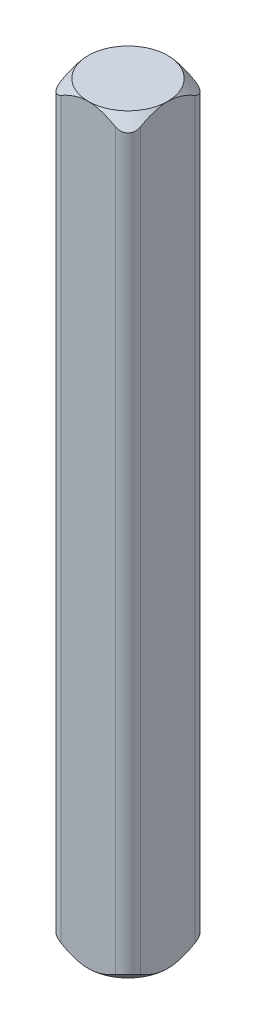
from build123d import *

# Parameters (mm, degrees)
SKETCH1_W           = 3.175
SKETCH1_H           = 3.175
BOSS_EXTRUDE1_DEPTH = 15
FILLET1_R           = 0.508


with BuildPart() as part:
    # Sketch1 → Boss-Extrude1 (new, symmetric)
    with BuildSketch(Plane(origin=(0, 0, 0), x_dir=(1, 0, 0), z_dir=(0, 1, 0))):
        Rectangle(SKETCH1_W, SKETCH1_H)
    extrude(amount=BOSS_EXTRUDE1_DEPTH, both=True)

    # Fillet1
    fillet1_edges = [part.edges().sort_by_distance(p)[0] for p in [
        (-1.5875, 0, -1.5875),
        (-1.5875, 0, 1.5875),
        (1.5875, 0, -1.5875),
        (1.5875, 0, 1.5875),
    ]]
    fillet(fillet1_edges, radius=FILLET1_R)

    # Sketch3 → Cut-Revolve3 (revolve, cut)
    with BuildSketch(Plane.XY):
        Polygon((1.5875, -15), (2.294606781, -14.292893219), (2.294606781, -16), (1.5875, -16), align=None)
    cut_revolve3 = revolve(axis=Axis((0, 0, 0), (0, -1, 0)), mode=Mode.SUBTRACT)

    # Mirror1: Cut-Revolve3 across plane
    add(cut_revolve3.mirror(Plane.ZX), mode=Mode.SUBTRACT)


solid = part.part
